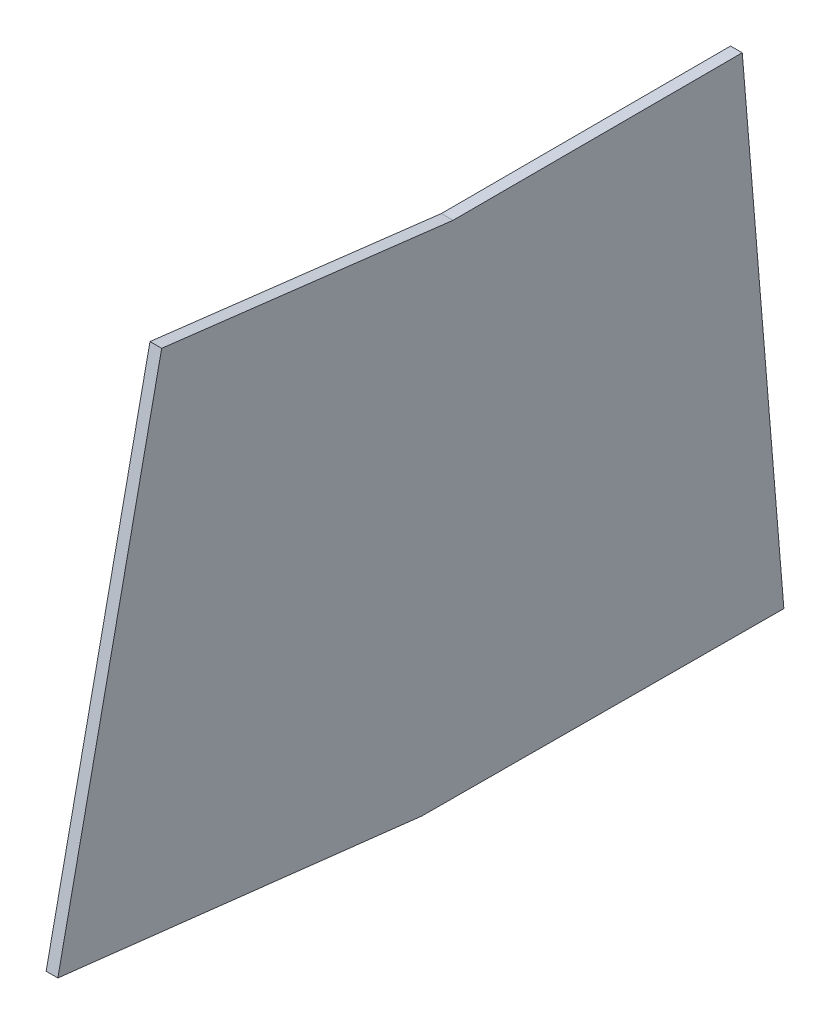
from build123d import *

# Parameters (mm, degrees)
BOSS_EXTRUDE1_DEPTH = 10


with BuildPart() as part:
    # Sketch1 → Boss-Extrude1 (new body)
    with BuildSketch(Plane(origin=(0, 0, 0), x_dir=(0, 0, -1), z_dir=(1, 0, 0))):
        Polygon((328.864745494, -228.582050483), (19.815533546, -227.382384297), (-291.281707896, -191.735889363), (-202.589751501, 229.705795793), (46.31163919, 199.964428642), (293.317457845, 200.38513346), align=None)
    extrude(amount=BOSS_EXTRUDE1_DEPTH)


solid = part.part
